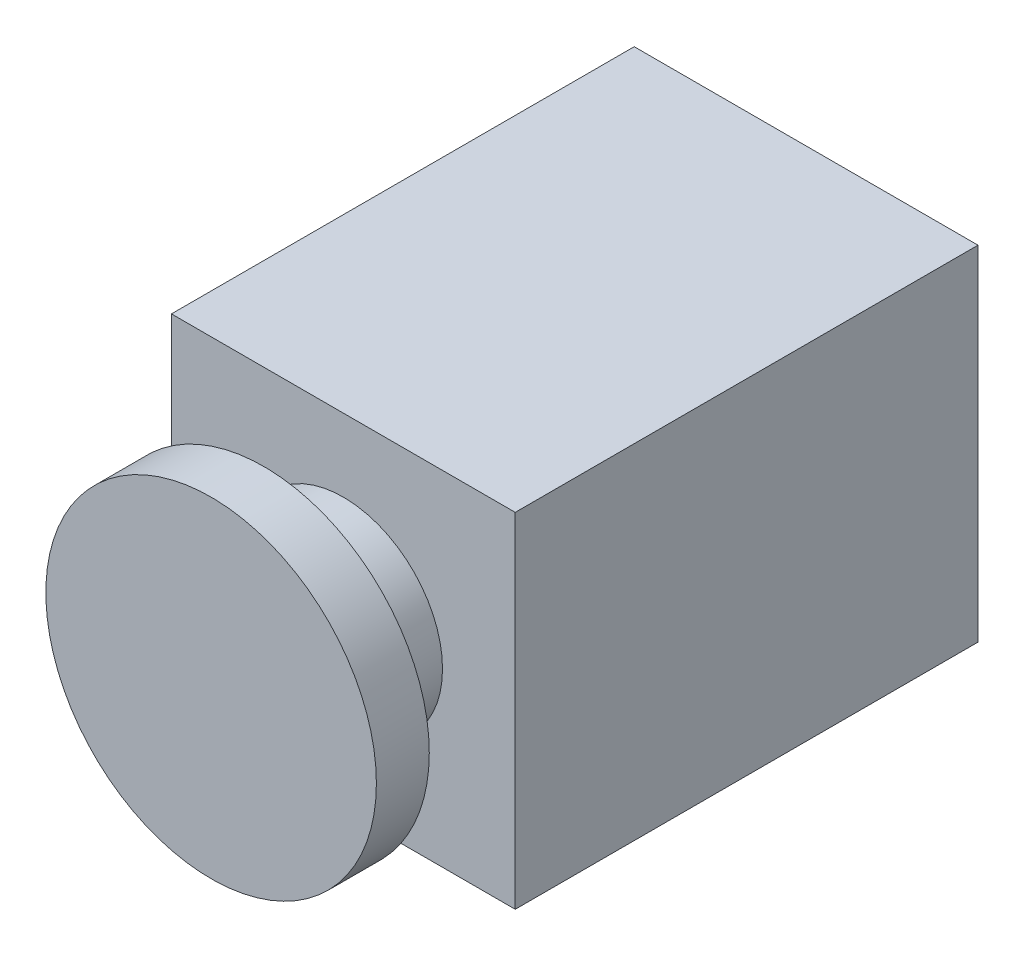
from build123d import *

# Parameters (mm, degrees)
SKETCH2_W           = 52
SKETCH2_H           = 52
BOSS_EXTRUDE1_DEPTH = 70
SKETCH3_R           = 15
BOSS_EXTRUDE2_DEPTH = 20
SKETCH4_R           = 1
CUT_EXTRUDE1_DEPTH  = 5
SKETCH5_R           = 25
BOSS_EXTRUDE3_DEPTH = 8


with BuildPart() as part:
    # Sketch2 → Boss-Extrude1 (new body)
    with BuildSketch(Plane.XY):
        Rectangle(SKETCH2_W, SKETCH2_H)
    extrude(amount=BOSS_EXTRUDE1_DEPTH)

    # Sketch3 → Boss-Extrude2 (add)
    with BuildSketch(Plane.XY.offset(70)):
        Circle(SKETCH3_R)
    extrude(amount=BOSS_EXTRUDE2_DEPTH)

    # Sketch4 → Cut-Extrude1 (cut)
    with BuildSketch(Plane.XZ.offset(26)):
        with Locations((-16.5, 62)):
            Circle(SKETCH4_R)
        with Locations((-16.5, 28.5)):
            Circle(SKETCH4_R)
        with Locations((-1.5, 62)):
            Circle(SKETCH4_R)
        with Locations((-1.5, 28.5)):
            Circle(SKETCH4_R)
        with Locations((-1.5, 7)):
            Circle(SKETCH4_R)
        with Locations((-16.5, 7)):
            Circle(SKETCH4_R)
    extrude(amount=-CUT_EXTRUDE1_DEPTH, mode=Mode.SUBTRACT)

    # Sketch5 → Boss-Extrude3 (add)
    with BuildSketch(Plane.XY.offset(90)):
        Circle(SKETCH5_R)
    extrude(amount=-BOSS_EXTRUDE3_DEPTH)


solid = part.part
